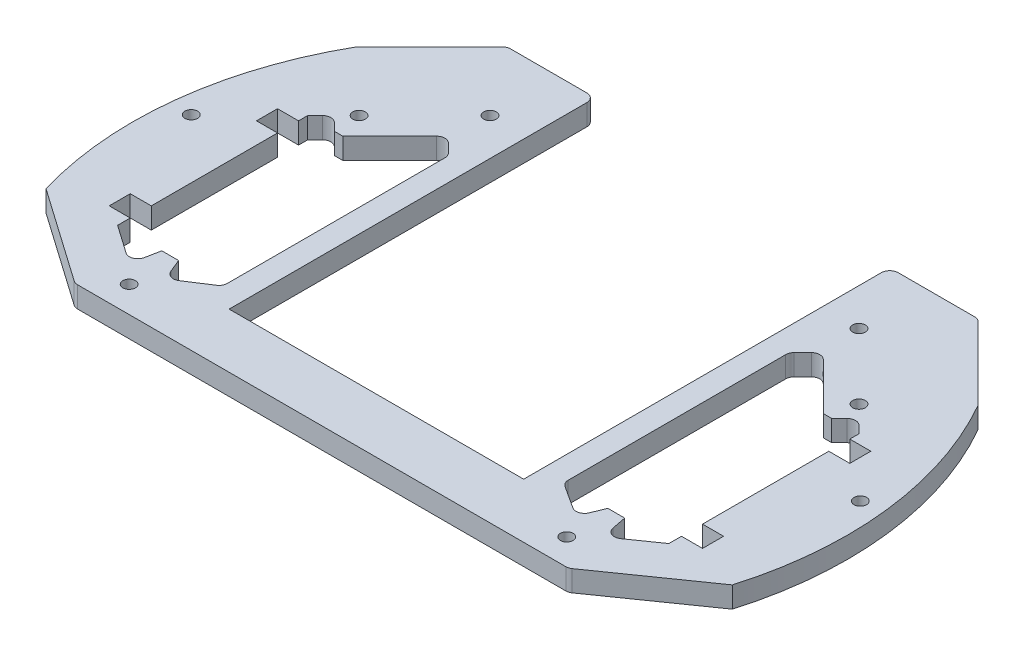
from build123d import *

# Parameters (mm, degrees)
SKETCH1_R            = 1.5
BOSS_EXTRUDE1_DEPTH  = 5
FILLET1_R            = 2
FILLET1_OF_MIRROR1_R = 2
FILLET2_R            = 2


with BuildPart() as part:
    # Sketch1 → Boss-Extrude1 (new body)
    with BuildSketch(Plane(origin=(0, 0, 0), x_dir=(1, 0, 0), z_dir=(0, 1, 0))):
        with BuildLine():
            Line((-58.655951842, -40), (-81.550499093, -23.96906543))
            ThreePointArc((-81.550499093, -23.96906543), (-84.423538078, 9.882622039), (-73.809947849, 42.155564266))
            Line((-73.809947849, 42.155564266), (-55.965512115, 60))
            Line((-55.965512115, 60), (-35, 60))
            Line((-35, 60), (-35, -27))
            Line((-35, -27), (0, -27))
            Line((0, -27), (0, -40))
            Line((0, -40), (-58.655951842, -40))
        make_face()
        with Locations((-43.840620434, 43.840620434)):
            Circle(SKETCH1_R, mode=Mode.SUBTRACT)
        with Locations((-51.997575213, -33.767620171)):
            Circle(SKETCH1_R, mode=Mode.SUBTRACT)
        with Locations((-59.39696962, 28.284271247)):
            Circle(SKETCH1_R, mode=Mode.SUBTRACT)
        with Locations((-79.5, 8.5)):
            Circle(SKETCH1_R, mode=Mode.SUBTRACT)
        Polygon((-65.5, 22.181240867), (-65.5, 20), (-70.5, 20), (-70.5, 15), (-65.5, 15), (-65.5, -15), (-70.5, -15), (-70.5, -20), (-65.5, -20), (-65.5, -23), (-56.256832596, -29.472135493), (-55, -23), (-51, -23), (-48.796166422, -28.387593469), (-40.5, -23), (-40.5, 30.600505063), (-44.547727215, 34.648232278), (-57.095959493, 22.1), (-59.095959493, 22.1), (-62.33860018, 25.342640687), align=None, mode=Mode.SUBTRACT)
    boss_extrude1 = extrude(amount=BOSS_EXTRUDE1_DEPTH)

    # Fillet1
    fillet1_edges = [part.edges().sort_by_distance(p)[0] for p in [
        (-44.547727215, 2.5, -34.648232278),
        (-62.33860018, 2.5, -25.342640687),
        (-56.256832596, 2.5, 29.472135493),
        (-48.796166422, 2.5, 28.387593469),
        (-40.5, 2.5, 23),
        (-40.5, 2.5, -30.600505063),
    ]]
    fillet(fillet1_edges, radius=FILLET1_R)

    # Mirror1: Boss-Extrude1 across plane
    add(boss_extrude1.mirror(Plane(origin=(0, 0, 0), x_dir=(0, 0, 1), z_dir=(1, 0, 0))))

    # Fillet1 of Mirror1
    fillet1_of_mirror1_edges = [part.edges().sort_by_distance(p)[0] for p in [
        (44.547727215, 2.5, -34.648232278),
        (62.33860018, 2.5, -25.342640687),
        (56.256832596, 2.5, 29.472135493),
        (48.796166422, 2.5, 28.387593469),
        (40.5, 2.5, 23),
        (40.5, 2.5, -30.600505063),
    ]]
    fillet(fillet1_of_mirror1_edges, radius=FILLET1_OF_MIRROR1_R)

    # Fillet2
    fillet2_edges = [part.edges().sort_by_distance(p)[0] for p in [
        (-55.965512115, 2.5, -60),
        (-35, 2.5, -60),
        (-58.655951842, 2.5, 40),
        (55.965512115, 2.5, -60),
        (35, 2.5, -60),
        (58.655951842, 2.5, 40),
    ]]
    fillet(fillet2_edges, radius=FILLET2_R)


solid = part.part
